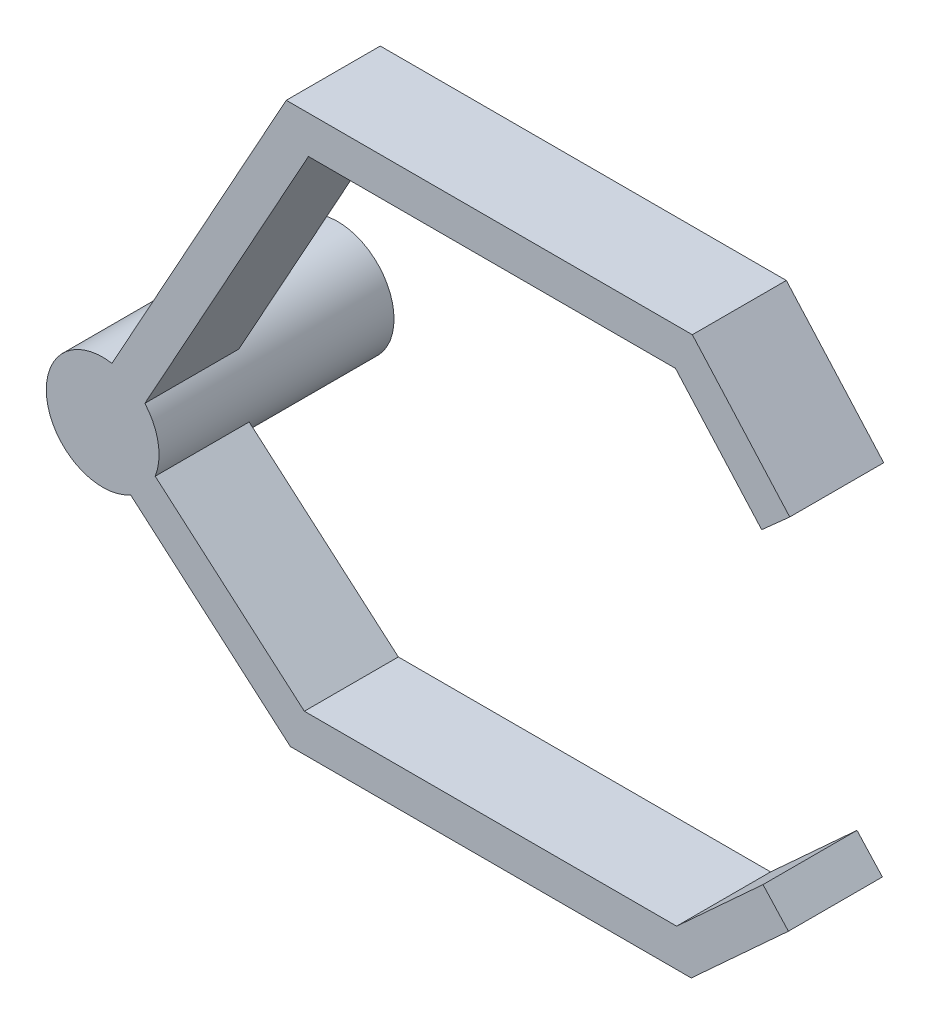
from build123d import *

# Parameters (mm, degrees)
BOSS_EXTRUDE1_DEPTH   = 10
BOSS_EXTRUDE1_2_DEPTH = 10
BOSS_EXTRUDE1_3_DEPTH = 10
BOSS_EXTRUDE1_4_DEPTH = 10
SKETCH2_R             = 6
BOSS_EXTRUDE2_DEPTH   = 25


with BuildPart() as part:
    # Sketch1 → Boss-Extrude1 (new body)
    with BuildSketch(Plane.XY):
        with BuildLine():
            Line((70.122128007, 25.154379147), (73.107309745, 27.816838535))
            Line((73.107309745, 27.816838535), (62.745195449, 39.434966685))
            Line((62.745195449, 39.434966685), (19.535932482, 39.434966685))
            Line((19.535932482, 39.434966685), (0.988958707, 5.917935508))
            ThreePointArc((0.988958707, 5.917935508), (2.90504438, 5.249830202), (4.488845509, 3.981239254))
            Line((4.488845509, 3.981239254), (21.894070174, 35.434966685))
            Line((21.894070174, 35.434966685), (60.952955338, 35.434966685))
            Line((60.952955338, 35.434966685), (70.122128007, 25.154379147))
        make_face()
    extrude(amount=BOSS_EXTRUDE1_DEPTH)


with BuildPart() as body_2:
    # Sketch1 → Boss-Extrude1 2 (new body)
    with BuildSketch(Plane.XY):
        with BuildLine():
            ThreePointArc((6, 0), (5.609504125, 2.129193151), (4.488845509, 3.981239254))
            Line((4.488845509, 3.981239254), (2.535804531, 0.451815201))
            Line((2.535804531, 0.451815201), (5.587664835, -2.185864062))
            ThreePointArc((5.587664835, -2.185864062), (5.896015138, -1.112207488), (6, 0))
        make_face()
    extrude(amount=BOSS_EXTRUDE1_2_DEPTH)


with BuildPart() as body_3:
    # Sketch1 → Boss-Extrude1 3 (new body)
    with BuildSketch(Plane.XY):
        with BuildLine():
            Line((-2.535804531, -0.451815201), (0.988958707, 5.917935508))
            ThreePointArc((0.988958707, 5.917935508), (-5.906970967, -1.052470426), (2.972059937, -5.212183777))
            Line((2.972059937, -5.212183777), (-2.535804531, -0.451815201))
        make_face()
    extrude(amount=BOSS_EXTRUDE1_3_DEPTH)


with BuildPart() as body_4:
    # Sketch1 → Boss-Extrude1 4 (new body)
    with BuildSketch(Plane.XY):
        with BuildLine():
            ThreePointArc((5.587664835, -2.185864062), (4.539479574, -3.923407346), (2.972059937, -5.212183777))
            Line((2.972059937, -5.212183777), (19.970484994, -19.903679719))
            Line((19.970484994, -19.903679719), (62.627042774, -19.903679719))
            Line((62.627042774, -19.903679719), (72.966168133, -10.42614814))
            Line((72.966168133, -10.42614814), (70.263269619, -7.477531579))
            Line((70.263269619, -7.477531579), (61.071108012, -15.903679719))
            Line((61.071108012, -15.903679719), (21.459517662, -15.903679719))
            Line((21.459517662, -15.903679719), (5.587664835, -2.185864062))
        make_face()
    extrude(amount=BOSS_EXTRUDE1_4_DEPTH)


with BuildPart() as boss_extrude2_tool:
    # Sketch2 → Boss-Extrude2 (new body)
    with BuildSketch(Plane.XY.offset(10)):
        Circle(SKETCH2_R)
    extrude(amount=-BOSS_EXTRUDE2_DEPTH)


with BuildPart() as part_1:
    add(part.part)


with BuildPart() as part_2:
    # Boss-Extrude2: joined with boss_extrude2_tool
    add(part_1.part.fuse(boss_extrude2_tool.part, body_2.part, body_3.part, body_4.part, tol=0.00001))


solid = part_2.part
